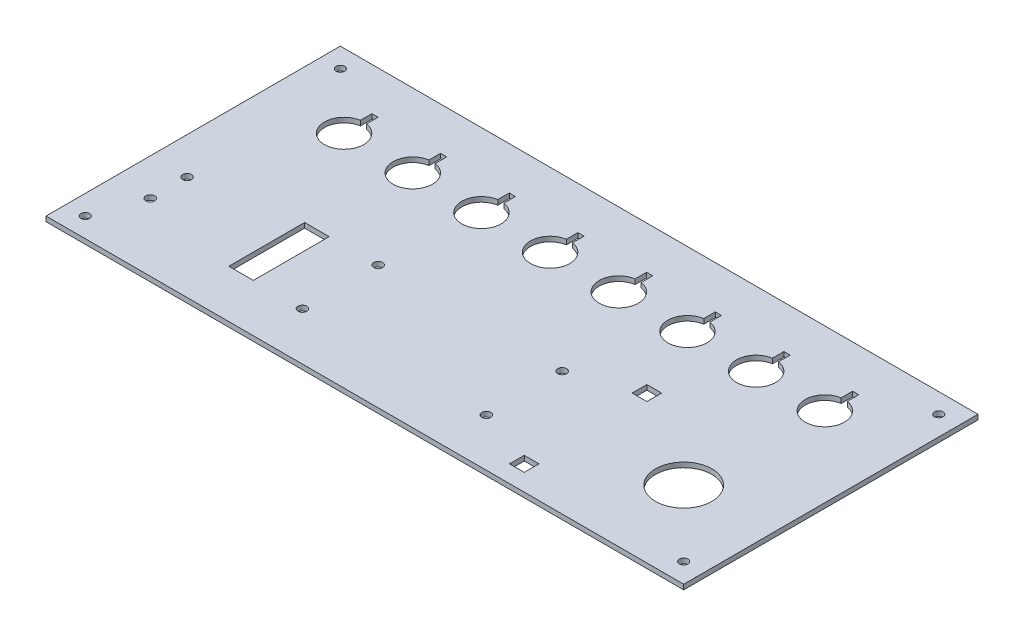
from build123d import *

# Parameters (mm, degrees)
SKETCH_1_W      = 260
SKETCH_1_H      = 120
SKETCH_1_R      = 1.8
SKETCH_1_R_2    = 11.5
SKETCH_1_R_3    = 1.75
SKETCH_1_W_2    = 10
SKETCH_1_H_2    = 30.9
SKETCH_1_W_3    = 6
SKETCH_1_H_3    = 6
EXTRUDE_1_DEPTH = 2


with BuildPart() as part:
    # 草圖1 → 填料-伸長1 (new body)
    with BuildSketch(Plane(origin=(0, 0, 0), x_dir=(1, 0, 0), z_dir=(0, 1, 0))):
        Rectangle(SKETCH_1_W, SKETCH_1_H)
        with Locations((-45, -9.55)):
            Circle(SKETCH_1_R, mode=Mode.SUBTRACT)
        with Locations((-45, -40.45)):
            Circle(SKETCH_1_R, mode=Mode.SUBTRACT)
        with Locations((30, -9.55)):
            Circle(SKETCH_1_R, mode=Mode.SUBTRACT)
        with Locations((30, -40.45)):
            Circle(SKETCH_1_R, mode=Mode.SUBTRACT)
        with Locations((95, -25)):
            Circle(SKETCH_1_R_2, mode=Mode.SUBTRACT)
        with Locations((-122, 52)):
            Circle(SKETCH_1_R_3, mode=Mode.SUBTRACT)
        with Locations((-122, -52)):
            Circle(SKETCH_1_R_3, mode=Mode.SUBTRACT)
        with Locations((122, 52)):
            Circle(SKETCH_1_R_3, mode=Mode.SUBTRACT)
        with Locations((122, -52)):
            Circle(SKETCH_1_R_3, mode=Mode.SUBTRACT)
        with Locations((-115, -17.5)):
            Circle(SKETCH_1_R, mode=Mode.SUBTRACT)
        with Locations((-115, -32.5)):
            Circle(SKETCH_1_R, mode=Mode.SUBTRACT)
        with Locations((-70, -25)):
            Rectangle(SKETCH_1_W_2, SKETCH_1_H_2, mode=Mode.SUBTRACT)
        with Locations((55, -50)):
            Rectangle(SKETCH_1_W_3, SKETCH_1_H_3, mode=Mode.SUBTRACT)
        with Locations((55, 0)):
            Rectangle(SKETCH_1_W_3, SKETCH_1_H_3, mode=Mode.SUBTRACT)
        with BuildLine():
            Line((-71.710967932, 42.596685205), (-69.210967932, 42.596685205))
            Line((-69.210967932, 42.596685205), (-69.210967932, 37.901740315))
            ThreePointArc((-69.210967932, 37.901740315), (-70.460967932, 22), (-71.710967932, 37.901740315))
            Line((-71.710967932, 37.901740315), (-71.710967932, 42.596685205))
        make_face(mode=Mode.SUBTRACT)
        with BuildLine():
            Line((-99.710967932, 42.596685205), (-97.210967932, 42.596685205))
            Line((-97.210967932, 42.596685205), (-97.210967932, 37.901740315))
            ThreePointArc((-97.210967932, 37.901740315), (-98.460967932, 22), (-99.710967932, 37.901740315))
            Line((-99.710967932, 37.901740315), (-99.710967932, 42.596685205))
        make_face(mode=Mode.SUBTRACT)
        with BuildLine():
            Line((-43.710967932, 42.596685205), (-41.210967932, 42.596685205))
            Line((-41.210967932, 42.596685205), (-41.210967932, 37.901740315))
            ThreePointArc((-41.210967932, 37.901740315), (-42.460967932, 22), (-43.710967932, 37.901740315))
            Line((-43.710967932, 37.901740315), (-43.710967932, 42.596685205))
        make_face(mode=Mode.SUBTRACT)
        with BuildLine():
            Line((-15.710967932, 42.596685205), (-13.210967932, 42.596685205))
            Line((-13.210967932, 42.596685205), (-13.210967932, 37.901740315))
            ThreePointArc((-13.210967932, 37.901740315), (-14.460967932, 22), (-15.710967932, 37.901740315))
            Line((-15.710967932, 37.901740315), (-15.710967932, 42.596685205))
        make_face(mode=Mode.SUBTRACT)
        with BuildLine():
            Line((12.289032068, 42.596685205), (14.789032068, 42.596685205))
            Line((14.789032068, 42.596685205), (14.789032068, 37.901740315))
            ThreePointArc((14.789032068, 37.901740315), (13.539032068, 22), (12.289032068, 37.901740315))
            Line((12.289032068, 37.901740315), (12.289032068, 42.596685205))
        make_face(mode=Mode.SUBTRACT)
        with BuildLine():
            Line((40.289032068, 42.596685205), (42.789032068, 42.596685205))
            Line((42.789032068, 42.596685205), (42.789032068, 37.901740315))
            ThreePointArc((42.789032068, 37.901740315), (41.539032068, 22), (40.289032068, 37.901740315))
            Line((40.289032068, 37.901740315), (40.289032068, 42.596685205))
        make_face(mode=Mode.SUBTRACT)
        with BuildLine():
            Line((68.289032068, 42.596685205), (70.789032068, 42.596685205))
            Line((70.789032068, 42.596685205), (70.789032068, 37.901740315))
            ThreePointArc((70.789032068, 37.901740315), (69.539032068, 22), (68.289032068, 37.901740315))
            Line((68.289032068, 37.901740315), (68.289032068, 42.596685205))
        make_face(mode=Mode.SUBTRACT)
        with BuildLine():
            Line((96.289032068, 42.596685205), (98.789032068, 42.596685205))
            Line((98.789032068, 42.596685205), (98.789032068, 37.901740315))
            ThreePointArc((98.789032068, 37.901740315), (97.539032068, 22), (96.289032068, 37.901740315))
            Line((96.289032068, 37.901740315), (96.289032068, 42.596685205))
        make_face(mode=Mode.SUBTRACT)
    extrude(amount=EXTRUDE_1_DEPTH)


solid = part.part
